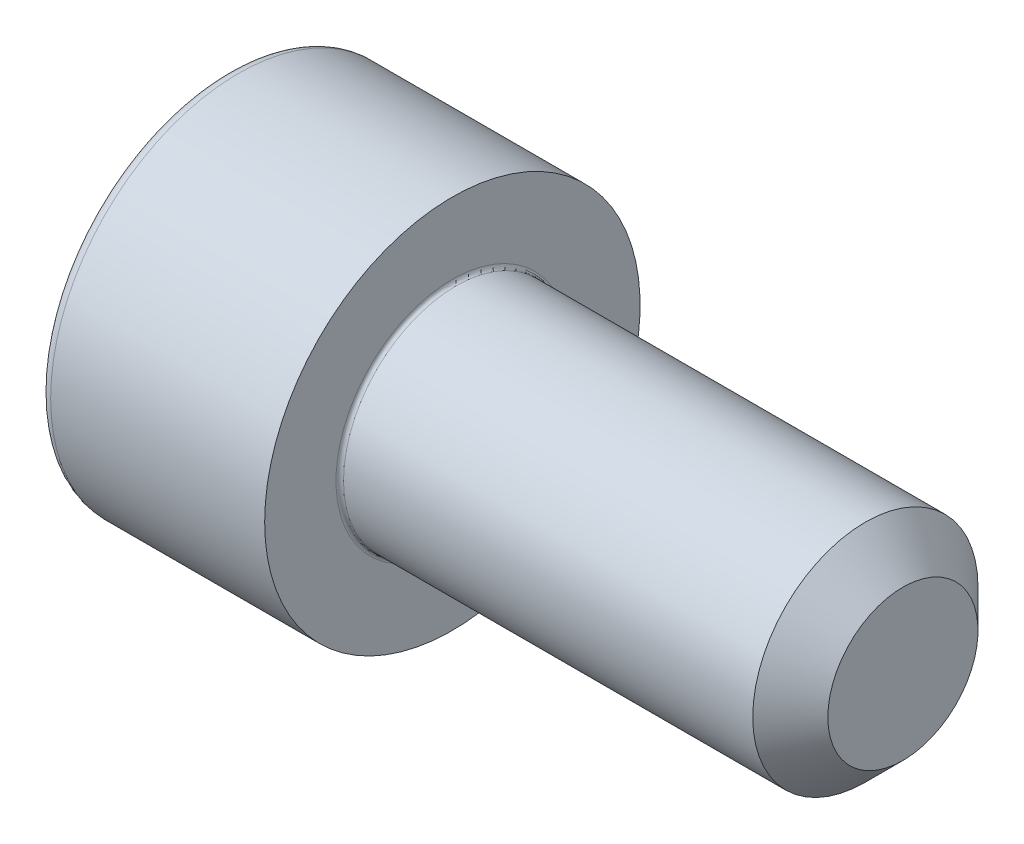
from build123d import *

# Parameters (mm, degrees)
FILLET1_R   = 0.1
FILLET2_R   = 0.3
HEX_2_DEPTH = 1.3


with BuildPart() as part:
    # BodySke → Base-Revolve (revolve)
    with BuildSketch(Plane.XY):
        Polygon((0, 0), (0, 5), (6, 5), (6, 3), (17, 3), (18, 2), (18, 0), align=None)
    revolve(axis=Axis((-31.75, 0, 0), (1, 0, 0)))

    # Fillet1
    fillet1_edges = [part.edges().sort_by_distance(p)[0] for p in [
        (6, -3, 0),
    ]]
    fillet(fillet1_edges, radius=FILLET1_R)

    # Fillet2
    fillet2_edges = [part.edges().sort_by_distance(p)[0] for p in [
        (0, -5, 0),
    ]]
    fillet(fillet2_edges, radius=FILLET2_R)

    # Sketch2 → Hex-PreBroach (revolve, cut)
    with BuildSketch(Plane.XY):
        Polygon((0, 2.5), (1.3, 2.5), (2.743375673, 0), (0, 0), align=None)
    revolve(axis=Axis((0, 0, 0), (1, 0, 0)), mode=Mode.SUBTRACT)

    # Sketch3 → Hex 2 (cut)
    with BuildSketch(Plane(origin=(0, 0, 0), x_dir=(0, 0.5, 0.866025404), z_dir=(-1, 0, 0))):
        Polygon((1.443375673, 2.5), (-1.443375673, 2.5), (-2.886751346, 0), (-1.443375673, -2.5), (1.443375673, -2.5), (2.886751346, 0), align=None)
    extrude(amount=-HEX_2_DEPTH, mode=Mode.SUBTRACT)


solid = part.part
